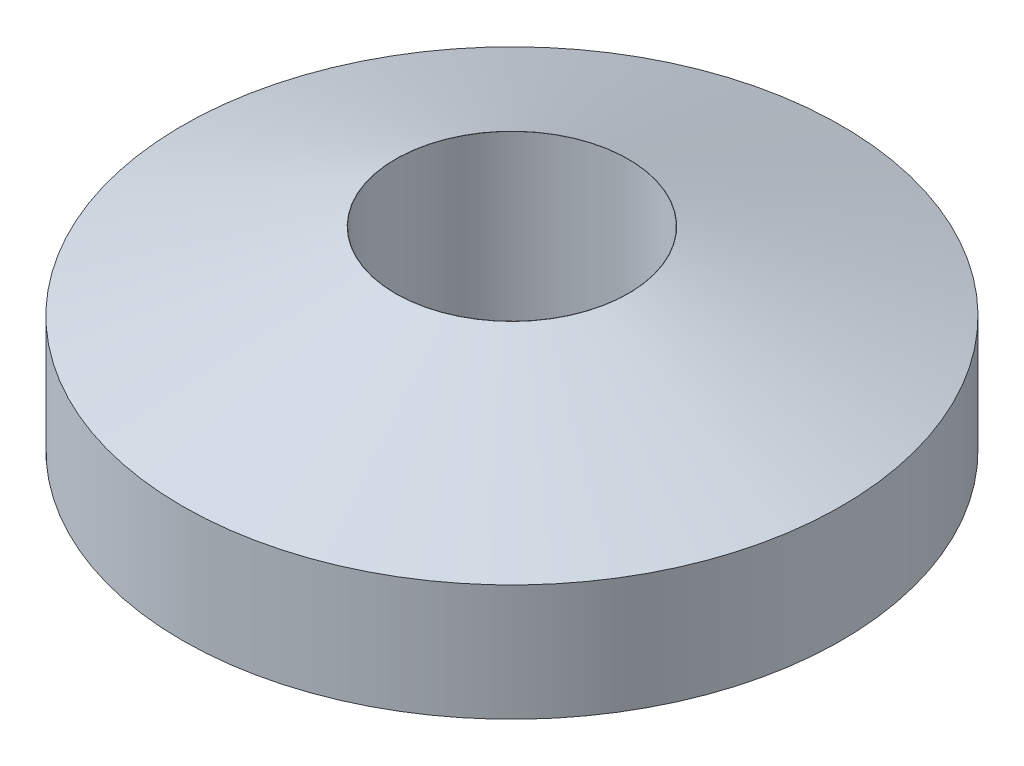
from build123d import *

# Parameters (mm, degrees)
CROQUIS1_R              = 8.5
SALIENTE_EXTRUIR1_DEPTH = 5
CROQUIS2_R              = 3
CORTAR_EXTRUIR1_DEPTH   = 15
CHAFL_N1_SIZE           = 2
CHAFL_N1_SIZE2          = 5.494954839


with BuildPart() as part:
    # Croquis1 → Saliente-Extruir1 (new body)
    with BuildSketch(Plane(origin=(0, 0, 0), x_dir=(1, 0, 0), z_dir=(0, 1, 0))):
        Circle(CROQUIS1_R)
    extrude(amount=SALIENTE_EXTRUIR1_DEPTH)

    # Croquis2 → Cortar-Extruir1 (cut)
    with BuildSketch(Plane(origin=(0, 5, 0), x_dir=(1, 0, 0), z_dir=(0, 1, 0))):
        Circle(CROQUIS2_R)
    extrude(amount=-CORTAR_EXTRUIR1_DEPTH, mode=Mode.SUBTRACT)

    # Chaflán1
    chafl_n1_edges = [part.edges().sort_by_distance(p)[0] for p in [
        (-8.5, 5, 0),
    ]]
    chafl_n1_side = [part.faces().sort_by_distance(p)[0] for p in [
        (-8.5, 2.5, 0),
    ]]
    chamfer(chafl_n1_edges, length=CHAFL_N1_SIZE, length2=CHAFL_N1_SIZE2, reference=chafl_n1_side[0])


solid = part.part
